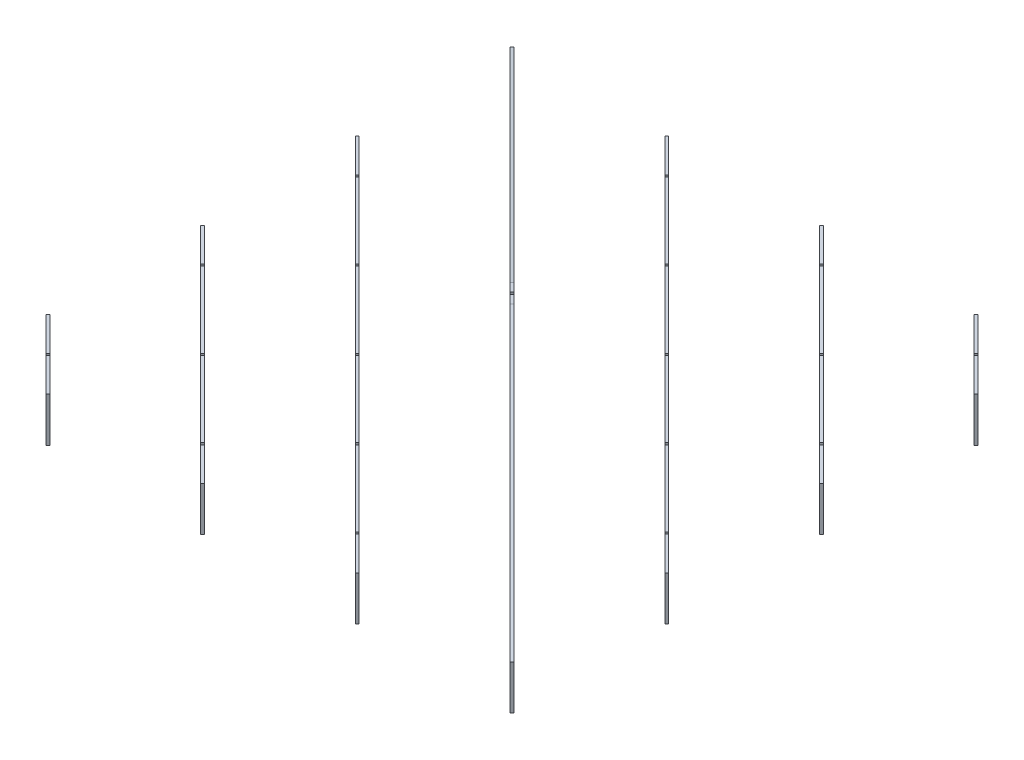
from build123d import *

# Parameters (mm, degrees)
BOSS_EXTRUDE1_DEPTH   = 100
BOSS_EXTRUDE1_2_DEPTH = 100
BOSS_EXTRUDE1_3_DEPTH = 100
BOSS_EXTRUDE1_4_DEPTH = 100
BOSS_EXTRUDE1_5_DEPTH = 100
BOSS_EXTRUDE1_6_DEPTH = 100
BOSS_EXTRUDE1_7_DEPTH = 100
BOSS_EXTRUDE2_START   = -6
BOSS_EXTRUDE2_DEPTH   = 6
SKETCH5_R             = 1.5
SKETCH5_W             = 6
SKETCH5_H             = 100
CUT_EXTRUDE1_DEPTH    = 500.974747
SKETCH6_R             = 1.5
SKETCH6_W             = 6
SKETCH6_H             = 100
CUT_EXTRUDE2_DEPTH    = 500.974747
CUT_EXTRUDE3_DEPTH    = 6
SKETCH8_W             = 56
SKETCH8_H             = 12
CUT_EXTRUDE4_DEPTH    = 6
SKETCH9_R             = 4
SKETCH9_R_2           = 10
CUT_EXTRUDE5_DEPTH    = 6
CUT_EXTRUDE6_START    = -6
SKETCH10_R            = 3
CUT_EXTRUDE6_DEPTH    = 253.487374


with BuildPart() as part:
    # Sketch2 → Boss-Extrude1 (new body)
    with BuildSketch(Plane(origin=(0, 0, 0), x_dir=(1, 0, 0), z_dir=(0, 1, 0))):
        Polygon((-605, -449.242640687), (-449.242640687, -605), (-445, -600.757359313), (-600.757359313, -445), align=None)
    extrude(amount=BOSS_EXTRUDE1_DEPTH)


with BuildPart() as body_2:
    # Sketch2 → Boss-Extrude1 2 (new body)
    with BuildSketch(Plane(origin=(0, 0, 0), x_dir=(1, 0, 0), z_dir=(0, 1, 0))):
        Polygon((-605, -99.242640687), (-99.242640687, -605), (-95, -600.757359313), (-600.757359313, -95), align=None)
    extrude(amount=BOSS_EXTRUDE1_2_DEPTH)


with BuildPart() as body_3:
    # Sketch2 → Boss-Extrude1 3 (new body)
    with BuildSketch(Plane(origin=(0, 0, 0), x_dir=(1, 0, 0), z_dir=(0, 1, 0))):
        Polygon((-605, 250.757359313), (250.757359313, -605), (255, -600.757359313), (-600.757359313, 255), align=None)
    extrude(amount=BOSS_EXTRUDE1_3_DEPTH)


with BuildPart() as body_4:
    # Sketch2 → Boss-Extrude1 4 (new body)
    with BuildSketch(Plane(origin=(0, 0, 0), x_dir=(1, 0, 0), z_dir=(0, 1, 0))):
        Polygon((605, -600.757359313), (-600.757359313, 605), (-605, 600.757359313), (600.757359313, -605), align=None)
    extrude(amount=BOSS_EXTRUDE1_4_DEPTH)

    # Sketch4 → Boss-Extrude2 (add)
    with BuildSketch(Plane(origin=(-2.121320344, 0, 2.121320344), x_dir=(0.707106781, 0, 0.707106781), z_dir=(-0.707106781, 0, 0.707106781)).offset(BOSS_EXTRUDE2_START)):
        Polygon((-30, 220), (-852.599205236, 100), (-30, 100), (30, 100), (852.599205236, 100), (30, 220), align=None)
    extrude(amount=BOSS_EXTRUDE2_DEPTH)

    # Sketch7 → Cut-Extrude3 (cut)
    with BuildSketch(Plane(origin=(-2.121320344, 0, 2.121320344), x_dir=(0.707106781, 0, 0.707106781), z_dir=(-0.707106781, 0, 0.707106781))):
        with BuildLine():
            ThreePointArc((-743.962120246, 50), (-746.522780418, 51.060660172), (-745.462120246, 48.5))
            Line((-745.462120246, 48.5), (-745.462120246, 50))
            Line((-745.462120246, 50), (-743.962120246, 50))
        make_face()
        with BuildLine():
            Line((-745.462120246, 50), (-745.462120246, 48.5))
            ThreePointArc((-745.462120246, 48.5), (-744.401460074, 48.939339828), (-743.962120246, 50))
            Line((-743.962120246, 50), (-745.462120246, 50))
        make_face()
        with BuildLine():
            ThreePointArc((-743.962120246, 50), (-746.522780418, 51.060660172), (-745.462120246, 48.5))
            Line((-745.462120246, 48.5), (-745.462120246, 50))
            Line((-745.462120246, 50), (-743.962120246, 50))
        make_face()
        with BuildLine():
            Line((-745.462120246, 50), (-745.462120246, 48.5))
            ThreePointArc((-745.462120246, 48.5), (-744.401460074, 48.939339828), (-743.962120246, 50))
            Line((-743.962120246, 50), (-745.462120246, 50))
        make_face()
        with BuildLine():
            Line((-745.462120246, 0), (-739.462120246, 0))
            Line((-739.462120246, 0), (-739.462120246, 48.5))
            ThreePointArc((-739.462120246, 48.5), (-740.522780418, 48.939339828), (-740.962120246, 50))
            Line((-740.962120246, 50), (-743.962120246, 50))
            ThreePointArc((-743.962120246, 50), (-744.401460074, 48.939339828), (-745.462120246, 48.5))
            Line((-745.462120246, 48.5), (-745.462120246, 0))
        make_face()
        with BuildLine():
            ThreePointArc((-740.962120246, 50), (-740.522780418, 48.939339828), (-739.462120246, 48.5))
            Line((-739.462120246, 48.5), (-739.462120246, 50))
            Line((-739.462120246, 50), (-740.962120246, 50))
        make_face()
        with BuildLine():
            Line((-739.462120246, 50), (-739.462120246, 48.5))
            ThreePointArc((-739.462120246, 48.5), (-738.401460074, 48.939339828), (-737.962120246, 50))
            ThreePointArc((-737.962120246, 50), (-739.462120246, 51.5), (-740.962120246, 50))
            Line((-740.962120246, 50), (-739.462120246, 50))
        make_face()
        with BuildLine():
            ThreePointArc((-740.962120246, 50), (-740.522780418, 48.939339828), (-739.462120246, 48.5))
            Line((-739.462120246, 48.5), (-739.462120246, 50))
            Line((-739.462120246, 50), (-740.962120246, 50))
        make_face()
        with BuildLine():
            Line((-739.462120246, 50), (-739.462120246, 48.5))
            ThreePointArc((-739.462120246, 48.5), (-738.401460074, 48.939339828), (-737.962120246, 50))
            ThreePointArc((-737.962120246, 50), (-739.462120246, 51.5), (-740.962120246, 50))
            Line((-740.962120246, 50), (-739.462120246, 50))
        make_face()
        with BuildLine():
            ThreePointArc((-496.474746831, 50), (-499.035407002, 51.060660172), (-497.974746831, 48.5))
            Line((-497.974746831, 48.5), (-497.974746831, 50))
            Line((-497.974746831, 50), (-496.474746831, 50))
        make_face()
        with BuildLine():
            Line((-497.974746831, 50), (-497.974746831, 48.5))
            ThreePointArc((-497.974746831, 48.5), (-496.914086659, 48.939339828), (-496.474746831, 50))
            Line((-496.474746831, 50), (-497.974746831, 50))
        make_face()
        with BuildLine():
            ThreePointArc((-496.474746831, 50), (-499.035407002, 51.060660172), (-497.974746831, 48.5))
            Line((-497.974746831, 48.5), (-497.974746831, 50))
            Line((-497.974746831, 50), (-496.474746831, 50))
        make_face()
        with BuildLine():
            Line((-497.974746831, 50), (-497.974746831, 48.5))
            ThreePointArc((-497.974746831, 48.5), (-496.914086659, 48.939339828), (-496.474746831, 50))
            Line((-496.474746831, 50), (-497.974746831, 50))
        make_face()
        with BuildLine():
            Line((-497.974746831, 0), (-491.974746831, 0))
            Line((-491.974746831, 0), (-491.974746831, 48.5))
            ThreePointArc((-491.974746831, 48.5), (-493.035407002, 48.939339828), (-493.474746831, 50))
            Line((-493.474746831, 50), (-496.474746831, 50))
            ThreePointArc((-496.474746831, 50), (-496.914086659, 48.939339828), (-497.974746831, 48.5))
            Line((-497.974746831, 48.5), (-497.974746831, 0))
        make_face()
        with BuildLine():
            ThreePointArc((-493.474746831, 50), (-493.035407002, 48.939339828), (-491.974746831, 48.5))
            Line((-491.974746831, 48.5), (-491.974746831, 50))
            Line((-491.974746831, 50), (-493.474746831, 50))
        make_face()
        with BuildLine():
            Line((-491.974746831, 50), (-491.974746831, 48.5))
            ThreePointArc((-491.974746831, 48.5), (-490.914086659, 48.939339828), (-490.474746831, 50))
            ThreePointArc((-490.474746831, 50), (-491.974746831, 51.5), (-493.474746831, 50))
            Line((-493.474746831, 50), (-491.974746831, 50))
        make_face()
        with BuildLine():
            ThreePointArc((-493.474746831, 50), (-493.035407002, 48.939339828), (-491.974746831, 48.5))
            Line((-491.974746831, 48.5), (-491.974746831, 50))
            Line((-491.974746831, 50), (-493.474746831, 50))
        make_face()
        with BuildLine():
            Line((-491.974746831, 50), (-491.974746831, 48.5))
            ThreePointArc((-491.974746831, 48.5), (-490.914086659, 48.939339828), (-490.474746831, 50))
            ThreePointArc((-490.474746831, 50), (-491.974746831, 51.5), (-493.474746831, 50))
            Line((-493.474746831, 50), (-491.974746831, 50))
        make_face()
        with BuildLine():
            ThreePointArc((-242.987373415, 50), (-244.487373415, 51.5), (-245.987373415, 50))
            Line((-245.987373415, 50), (-244.487373415, 50))
            Line((-244.487373415, 50), (-244.487373415, 48.5))
            ThreePointArc((-244.487373415, 48.5), (-243.426713244, 48.939339828), (-242.987373415, 50))
        make_face()
        with BuildLine():
            Line((-244.487373415, 50), (-245.987373415, 50))
            ThreePointArc((-245.987373415, 50), (-245.548033587, 48.939339828), (-244.487373415, 48.5))
            Line((-244.487373415, 48.5), (-244.487373415, 50))
        make_face()
        with BuildLine():
            ThreePointArc((-242.987373415, 50), (-244.487373415, 51.5), (-245.987373415, 50))
            Line((-245.987373415, 50), (-244.487373415, 50))
            Line((-244.487373415, 50), (-244.487373415, 48.5))
            ThreePointArc((-244.487373415, 48.5), (-243.426713244, 48.939339828), (-242.987373415, 50))
        make_face()
        with BuildLine():
            Line((-244.487373415, 50), (-245.987373415, 50))
            ThreePointArc((-245.987373415, 50), (-245.548033587, 48.939339828), (-244.487373415, 48.5))
            Line((-244.487373415, 48.5), (-244.487373415, 50))
        make_face()
        with BuildLine():
            Line((-245.987373415, 50), (-248.987373415, 50))
            ThreePointArc((-248.987373415, 50), (-249.426713244, 48.939339828), (-250.487373415, 48.5))
            Line((-250.487373415, 48.5), (-250.487373415, 0))
            Line((-250.487373415, 0), (-244.487373415, 0))
            Line((-244.487373415, 0), (-244.487373415, 48.5))
            ThreePointArc((-244.487373415, 48.5), (-245.548033587, 48.939339828), (-245.987373415, 50))
        make_face()
        with BuildLine():
            Line((-250.487373415, 48.5), (-250.487373415, 50))
            Line((-250.487373415, 50), (-248.987373415, 50))
            ThreePointArc((-248.987373415, 50), (-251.548033587, 51.060660172), (-250.487373415, 48.5))
        make_face()
        with BuildLine():
            Line((-248.987373415, 50), (-250.487373415, 50))
            Line((-250.487373415, 50), (-250.487373415, 48.5))
            ThreePointArc((-250.487373415, 48.5), (-249.426713244, 48.939339828), (-248.987373415, 50))
        make_face()
        with BuildLine():
            Line((-250.487373415, 48.5), (-250.487373415, 50))
            Line((-250.487373415, 50), (-248.987373415, 50))
            ThreePointArc((-248.987373415, 50), (-251.548033587, 51.060660172), (-250.487373415, 48.5))
        make_face()
        with BuildLine():
            Line((-248.987373415, 50), (-250.487373415, 50))
            Line((-250.487373415, 50), (-250.487373415, 48.5))
            ThreePointArc((-250.487373415, 48.5), (-249.426713244, 48.939339828), (-248.987373415, 50))
        make_face()
        with BuildLine():
            Line((3, 220), (-3, 220))
            Line((-3, 220), (-3, 111.5))
            ThreePointArc((-3, 111.5), (-1.939339828, 111.060660172), (-1.5, 110))
            Line((-1.5, 110), (1.5, 110))
            ThreePointArc((1.5, 110), (1.939339828, 111.060660172), (3, 111.5))
            Line((3, 111.5), (3, 220))
        make_face()
        with BuildLine():
            ThreePointArc((-1.5, 110), (-1.939339828, 111.060660172), (-3, 111.5))
            Line((-3, 111.5), (-3, 110))
            Line((-3, 110), (-1.5, 110))
        make_face()
        with BuildLine():
            Line((-3, 110), (-3, 111.5))
            ThreePointArc((-3, 111.5), (-4.060660172, 108.939339828), (-1.5, 110))
            Line((-1.5, 110), (-3, 110))
        make_face()
        with BuildLine():
            ThreePointArc((-1.5, 110), (-1.939339828, 111.060660172), (-3, 111.5))
            Line((-3, 111.5), (-3, 110))
            Line((-3, 110), (-1.5, 110))
        make_face()
        with BuildLine():
            Line((-3, 110), (-3, 111.5))
            ThreePointArc((-3, 111.5), (-4.060660172, 108.939339828), (-1.5, 110))
            Line((-1.5, 110), (-3, 110))
        make_face()
        with BuildLine():
            ThreePointArc((4.5, 110), (4.060660172, 111.060660172), (3, 111.5))
            Line((3, 111.5), (3, 110))
            Line((3, 110), (1.5, 110))
            ThreePointArc((1.5, 110), (3, 108.5), (4.5, 110))
        make_face()
        with BuildLine():
            Line((3, 110), (3, 111.5))
            ThreePointArc((3, 111.5), (1.939339828, 111.060660172), (1.5, 110))
            Line((1.5, 110), (3, 110))
        make_face()
        with BuildLine():
            ThreePointArc((4.5, 110), (4.060660172, 111.060660172), (3, 111.5))
            Line((3, 111.5), (3, 110))
            Line((3, 110), (1.5, 110))
            ThreePointArc((1.5, 110), (3, 108.5), (4.5, 110))
        make_face()
        with BuildLine():
            Line((3, 110), (3, 111.5))
            ThreePointArc((3, 111.5), (1.939339828, 111.060660172), (1.5, 110))
            Line((1.5, 110), (3, 110))
        make_face()
        with BuildLine():
            ThreePointArc((245.987373415, 50), (243.426713244, 51.060660172), (244.487373415, 48.5))
            Line((244.487373415, 48.5), (244.487373415, 50))
            Line((244.487373415, 50), (245.987373415, 50))
        make_face()
        with BuildLine():
            Line((244.487373415, 50), (244.487373415, 48.5))
            ThreePointArc((244.487373415, 48.5), (245.548033587, 48.939339828), (245.987373415, 50))
            Line((245.987373415, 50), (244.487373415, 50))
        make_face()
        with BuildLine():
            ThreePointArc((245.987373415, 50), (243.426713244, 51.060660172), (244.487373415, 48.5))
            Line((244.487373415, 48.5), (244.487373415, 50))
            Line((244.487373415, 50), (245.987373415, 50))
        make_face()
        with BuildLine():
            Line((244.487373415, 50), (244.487373415, 48.5))
            ThreePointArc((244.487373415, 48.5), (245.548033587, 48.939339828), (245.987373415, 50))
            Line((245.987373415, 50), (244.487373415, 50))
        make_face()
        with BuildLine():
            Line((244.487373415, 48.5), (244.487373415, 0))
            Line((244.487373415, 0), (250.487373415, 0))
            Line((250.487373415, 0), (250.487373415, 48.5))
            ThreePointArc((250.487373415, 48.5), (249.426713244, 48.939339828), (248.987373415, 50))
            Line((248.987373415, 50), (245.987373415, 50))
            ThreePointArc((245.987373415, 50), (245.548033587, 48.939339828), (244.487373415, 48.5))
        make_face()
        with BuildLine():
            ThreePointArc((248.987373415, 50), (249.426713244, 48.939339828), (250.487373415, 48.5))
            Line((250.487373415, 48.5), (250.487373415, 50))
            Line((250.487373415, 50), (248.987373415, 50))
        make_face()
        with BuildLine():
            Line((250.487373415, 50), (250.487373415, 48.5))
            ThreePointArc((250.487373415, 48.5), (251.548033587, 48.939339828), (251.987373415, 50))
            ThreePointArc((251.987373415, 50), (250.487373415, 51.5), (248.987373415, 50))
            Line((248.987373415, 50), (250.487373415, 50))
        make_face()
        with BuildLine():
            ThreePointArc((248.987373415, 50), (249.426713244, 48.939339828), (250.487373415, 48.5))
            Line((250.487373415, 48.5), (250.487373415, 50))
            Line((250.487373415, 50), (248.987373415, 50))
        make_face()
        with BuildLine():
            Line((250.487373415, 50), (250.487373415, 48.5))
            ThreePointArc((250.487373415, 48.5), (251.548033587, 48.939339828), (251.987373415, 50))
            ThreePointArc((251.987373415, 50), (250.487373415, 51.5), (248.987373415, 50))
            Line((248.987373415, 50), (250.487373415, 50))
        make_face()
        with BuildLine():
            ThreePointArc((493.474746831, 50), (490.914086659, 51.060660172), (491.974746831, 48.5))
            Line((491.974746831, 48.5), (491.974746831, 50))
            Line((491.974746831, 50), (493.474746831, 50))
        make_face()
        with BuildLine():
            Line((491.974746831, 50), (491.974746831, 48.5))
            ThreePointArc((491.974746831, 48.5), (493.035407002, 48.939339828), (493.474746831, 50))
            Line((493.474746831, 50), (491.974746831, 50))
        make_face()
        with BuildLine():
            ThreePointArc((493.474746831, 50), (490.914086659, 51.060660172), (491.974746831, 48.5))
            Line((491.974746831, 48.5), (491.974746831, 50))
            Line((491.974746831, 50), (493.474746831, 50))
        make_face()
        with BuildLine():
            Line((491.974746831, 50), (491.974746831, 48.5))
            ThreePointArc((491.974746831, 48.5), (493.035407002, 48.939339828), (493.474746831, 50))
            Line((493.474746831, 50), (491.974746831, 50))
        make_face()
        with BuildLine():
            Line((491.974746831, 48.5), (491.974746831, 0))
            Line((491.974746831, 0), (497.974746831, 0))
            Line((497.974746831, 0), (497.974746831, 48.5))
            ThreePointArc((497.974746831, 48.5), (496.914086659, 48.939339828), (496.474746831, 50))
            Line((496.474746831, 50), (493.474746831, 50))
            ThreePointArc((493.474746831, 50), (493.035407002, 48.939339828), (491.974746831, 48.5))
        make_face()
        with BuildLine():
            ThreePointArc((496.474746831, 50), (496.914086659, 48.939339828), (497.974746831, 48.5))
            Line((497.974746831, 48.5), (497.974746831, 50))
            Line((497.974746831, 50), (496.474746831, 50))
        make_face()
        with BuildLine():
            Line((497.974746831, 50), (497.974746831, 48.5))
            ThreePointArc((497.974746831, 48.5), (499.035407002, 48.939339828), (499.474746831, 50))
            ThreePointArc((499.474746831, 50), (497.974746831, 51.5), (496.474746831, 50))
            Line((496.474746831, 50), (497.974746831, 50))
        make_face()
        with BuildLine():
            ThreePointArc((496.474746831, 50), (496.914086659, 48.939339828), (497.974746831, 48.5))
            Line((497.974746831, 48.5), (497.974746831, 50))
            Line((497.974746831, 50), (496.474746831, 50))
        make_face()
        with BuildLine():
            Line((497.974746831, 50), (497.974746831, 48.5))
            ThreePointArc((497.974746831, 48.5), (499.035407002, 48.939339828), (499.474746831, 50))
            ThreePointArc((499.474746831, 50), (497.974746831, 51.5), (496.474746831, 50))
            Line((496.474746831, 50), (497.974746831, 50))
        make_face()
        with BuildLine():
            ThreePointArc((740.962120246, 50), (738.401460074, 51.060660172), (739.462120246, 48.5))
            Line((739.462120246, 48.5), (739.462120246, 50))
            Line((739.462120246, 50), (740.962120246, 50))
        make_face()
        with BuildLine():
            Line((739.462120246, 50), (739.462120246, 48.5))
            ThreePointArc((739.462120246, 48.5), (740.522780418, 48.939339828), (740.962120246, 50))
            Line((740.962120246, 50), (739.462120246, 50))
        make_face()
        with BuildLine():
            ThreePointArc((740.962120246, 50), (738.401460074, 51.060660172), (739.462120246, 48.5))
            Line((739.462120246, 48.5), (739.462120246, 50))
            Line((739.462120246, 50), (740.962120246, 50))
        make_face()
        with BuildLine():
            Line((739.462120246, 50), (739.462120246, 48.5))
            ThreePointArc((739.462120246, 48.5), (740.522780418, 48.939339828), (740.962120246, 50))
            Line((740.962120246, 50), (739.462120246, 50))
        make_face()
        with BuildLine():
            Line((739.462120246, 48.5), (739.462120246, 0))
            Line((739.462120246, 0), (745.462120246, 0))
            Line((745.462120246, 0), (745.462120246, 48.5))
            ThreePointArc((745.462120246, 48.5), (744.401460074, 48.939339828), (743.962120246, 50))
            Line((743.962120246, 50), (740.962120246, 50))
            ThreePointArc((740.962120246, 50), (740.522780418, 48.939339828), (739.462120246, 48.5))
        make_face()
        with BuildLine():
            ThreePointArc((743.962120246, 50), (744.401460074, 48.939339828), (745.462120246, 48.5))
            Line((745.462120246, 48.5), (745.462120246, 50))
            Line((745.462120246, 50), (743.962120246, 50))
        make_face()
        with BuildLine():
            Line((745.462120246, 50), (745.462120246, 48.5))
            ThreePointArc((745.462120246, 48.5), (746.522780418, 48.939339828), (746.962120246, 50))
            ThreePointArc((746.962120246, 50), (745.462120246, 51.5), (743.962120246, 50))
            Line((743.962120246, 50), (745.462120246, 50))
        make_face()
        with BuildLine():
            ThreePointArc((743.962120246, 50), (744.401460074, 48.939339828), (745.462120246, 48.5))
            Line((745.462120246, 48.5), (745.462120246, 50))
            Line((745.462120246, 50), (743.962120246, 50))
        make_face()
        with BuildLine():
            Line((745.462120246, 50), (745.462120246, 48.5))
            ThreePointArc((745.462120246, 48.5), (746.522780418, 48.939339828), (746.962120246, 50))
            ThreePointArc((746.962120246, 50), (745.462120246, 51.5), (743.962120246, 50))
            Line((743.962120246, 50), (745.462120246, 50))
        make_face()
    extrude(amount=-CUT_EXTRUDE3_DEPTH, mode=Mode.SUBTRACT)

    # Sketch8 → Cut-Extrude4 (cut)
    with BuildSketch(Plane(origin=(-2.121320344, 0, 2.121320344), x_dir=(0.707106781, 0, 0.707106781), z_dir=(-0.707106781, 0, 0.707106781))):
        with Locations((371.231060123, 22)):
            Rectangle(SKETCH8_W, SKETCH8_H)
        with Locations((-371.231060123, 22)):
            Rectangle(SKETCH8_W, SKETCH8_H)
    extrude(amount=-CUT_EXTRUDE4_DEPTH, mode=Mode.SUBTRACT)

    # Sketch9 → Cut-Extrude5 (cut)
    with BuildSketch(Plane(origin=(2.121320344, 0, -2.121320344), x_dir=(-0.707106781, 0, -0.707106781), z_dir=(0.707106781, 0, -0.707106781))):
        with Locations((123.743686708, 64)):
            Circle(SKETCH9_R)
        with Locations((123.743686708, 84)):
            Circle(SKETCH9_R)
        with Locations((40, 74)):
            Circle(SKETCH9_R_2)
        with Locations((-40, 74)):
            Circle(SKETCH9_R_2)
        with Locations((-123.743686708, 84)):
            Circle(SKETCH9_R)
        with Locations((-123.743686708, 64)):
            Circle(SKETCH9_R)
    extrude(amount=-CUT_EXTRUDE5_DEPTH, mode=Mode.SUBTRACT)


with BuildPart() as body_5:
    # Sketch2 → Boss-Extrude1 5 (new body)
    with BuildSketch(Plane(origin=(0, 0, 0), x_dir=(1, 0, 0), z_dir=(0, 1, 0))):
        Polygon((-255, 600.757359313), (600.757359313, -255), (605, -250.757359313), (-250.757359313, 605), align=None)
    extrude(amount=BOSS_EXTRUDE1_5_DEPTH)


with BuildPart() as body_6:
    # Sketch2 → Boss-Extrude1 6 (new body)
    with BuildSketch(Plane(origin=(0, 0, 0), x_dir=(1, 0, 0), z_dir=(0, 1, 0))):
        Polygon((95, 600.757359313), (600.757359313, 95), (605, 99.242640687), (99.242640687, 605), align=None)
    extrude(amount=BOSS_EXTRUDE1_6_DEPTH)


with BuildPart() as body_7:
    # Sketch2 → Boss-Extrude1 7 (new body)
    with BuildSketch(Plane(origin=(0, 0, 0), x_dir=(1, 0, 0), z_dir=(0, 1, 0))):
        Polygon((445, 600.757359313), (600.757359313, 445), (605, 449.242640687), (449.242640687, 605), align=None)
    extrude(amount=BOSS_EXTRUDE1_7_DEPTH)


with BuildPart() as cut_extrude1_tool:
    # Sketch5 → Cut-Extrude1 (new body)
    with BuildSketch(Plane(origin=(-527.121320344, 0, 527.121320344), x_dir=(0.707106781, 0, 0.707106781), z_dir=(-0.707106781, 0, 0.707106781))):
        with Locations((497.974746831, 50)):
            Circle(SKETCH5_R)
        with Locations((491.974746831, 50)):
            Circle(SKETCH5_R)
        with Locations((494.974746831, 100)):
            Rectangle(SKETCH5_W, SKETCH5_H)
        with BuildLine():
            ThreePointArc((493.474746831, 50), (493.035407002, 51.060660172), (491.974746831, 51.5))
            Line((491.974746831, 51.5), (491.974746831, 50))
            Line((491.974746831, 50), (493.474746831, 50))
        make_face()
        with BuildLine():
            Line((491.974746831, 50), (491.974746831, 51.5))
            ThreePointArc((491.974746831, 51.5), (490.914086659, 48.939339828), (493.474746831, 50))
            Line((493.474746831, 50), (491.974746831, 50))
        make_face()
        with BuildLine():
            ThreePointArc((493.474746831, 50), (493.035407002, 51.060660172), (491.974746831, 51.5))
            Line((491.974746831, 51.5), (491.974746831, 50))
            Line((491.974746831, 50), (493.474746831, 50))
        make_face()
        with BuildLine():
            Line((491.974746831, 50), (491.974746831, 51.5))
            ThreePointArc((491.974746831, 51.5), (490.914086659, 48.939339828), (493.474746831, 50))
            Line((493.474746831, 50), (491.974746831, 50))
        make_face()
        with BuildLine():
            ThreePointArc((499.474746831, 50), (499.035407002, 51.060660172), (497.974746831, 51.5))
            Line((497.974746831, 51.5), (497.974746831, 50))
            Line((497.974746831, 50), (496.474746831, 50))
            ThreePointArc((496.474746831, 50), (497.974746831, 48.5), (499.474746831, 50))
        make_face()
        with BuildLine():
            Line((497.974746831, 50), (497.974746831, 51.5))
            ThreePointArc((497.974746831, 51.5), (496.914086659, 51.060660172), (496.474746831, 50))
            Line((496.474746831, 50), (497.974746831, 50))
        make_face()
        with BuildLine():
            ThreePointArc((499.474746831, 50), (499.035407002, 51.060660172), (497.974746831, 51.5))
            Line((497.974746831, 51.5), (497.974746831, 50))
            Line((497.974746831, 50), (496.474746831, 50))
            ThreePointArc((496.474746831, 50), (497.974746831, 48.5), (499.474746831, 50))
        make_face()
        with BuildLine():
            Line((497.974746831, 50), (497.974746831, 51.5))
            ThreePointArc((497.974746831, 51.5), (496.914086659, 51.060660172), (496.474746831, 50))
            Line((496.474746831, 50), (497.974746831, 50))
        make_face()
        with Locations((250.487373415, 50)):
            Circle(SKETCH5_R)
        with Locations((244.487373415, 50)):
            Circle(SKETCH5_R)
        with Locations((247.487373415, 100)):
            Rectangle(SKETCH5_W, SKETCH5_H)
        with BuildLine():
            ThreePointArc((245.987373415, 50), (245.548033587, 51.060660172), (244.487373415, 51.5))
            Line((244.487373415, 51.5), (244.487373415, 50))
            Line((244.487373415, 50), (245.987373415, 50))
        make_face()
        with BuildLine():
            Line((244.487373415, 50), (244.487373415, 51.5))
            ThreePointArc((244.487373415, 51.5), (243.426713244, 48.939339828), (245.987373415, 50))
            Line((245.987373415, 50), (244.487373415, 50))
        make_face()
        with BuildLine():
            ThreePointArc((245.987373415, 50), (245.548033587, 51.060660172), (244.487373415, 51.5))
            Line((244.487373415, 51.5), (244.487373415, 50))
            Line((244.487373415, 50), (245.987373415, 50))
        make_face()
        with BuildLine():
            Line((244.487373415, 50), (244.487373415, 51.5))
            ThreePointArc((244.487373415, 51.5), (243.426713244, 48.939339828), (245.987373415, 50))
            Line((245.987373415, 50), (244.487373415, 50))
        make_face()
        with BuildLine():
            ThreePointArc((251.987373415, 50), (251.548033587, 51.060660172), (250.487373415, 51.5))
            Line((250.487373415, 51.5), (250.487373415, 50))
            Line((250.487373415, 50), (248.987373415, 50))
            ThreePointArc((248.987373415, 50), (250.487373415, 48.5), (251.987373415, 50))
        make_face()
        with BuildLine():
            Line((250.487373415, 50), (250.487373415, 51.5))
            ThreePointArc((250.487373415, 51.5), (249.426713244, 51.060660172), (248.987373415, 50))
            Line((248.987373415, 50), (250.487373415, 50))
        make_face()
        with BuildLine():
            ThreePointArc((251.987373415, 50), (251.548033587, 51.060660172), (250.487373415, 51.5))
            Line((250.487373415, 51.5), (250.487373415, 50))
            Line((250.487373415, 50), (248.987373415, 50))
            ThreePointArc((248.987373415, 50), (250.487373415, 48.5), (251.987373415, 50))
        make_face()
        with BuildLine():
            Line((250.487373415, 50), (250.487373415, 51.5))
            ThreePointArc((250.487373415, 51.5), (249.426713244, 51.060660172), (248.987373415, 50))
            Line((248.987373415, 50), (250.487373415, 50))
        make_face()
        with BuildLine():
            Line((3, 100), (-3, 100))
            Line((-3, 100), (-3, 51.5))
            ThreePointArc((-3, 51.5), (-1.939339828, 51.060660172), (-1.5, 50))
            Line((-1.5, 50), (1.5, 50))
            ThreePointArc((1.5, 50), (1.939339828, 51.060660172), (3, 51.5))
            Line((3, 51.5), (3, 100))
        make_face()
        with BuildLine():
            ThreePointArc((-1.5, 50), (-1.939339828, 51.060660172), (-3, 51.5))
            Line((-3, 51.5), (-3, 50))
            Line((-3, 50), (-1.5, 50))
        make_face()
        with BuildLine():
            Line((-3, 50), (-3, 51.5))
            ThreePointArc((-3, 51.5), (-4.060660172, 48.939339828), (-1.5, 50))
            Line((-1.5, 50), (-3, 50))
        make_face()
        with BuildLine():
            ThreePointArc((-1.5, 50), (-1.939339828, 51.060660172), (-3, 51.5))
            Line((-3, 51.5), (-3, 50))
            Line((-3, 50), (-1.5, 50))
        make_face()
        with BuildLine():
            Line((-3, 50), (-3, 51.5))
            ThreePointArc((-3, 51.5), (-4.060660172, 48.939339828), (-1.5, 50))
            Line((-1.5, 50), (-3, 50))
        make_face()
        with BuildLine():
            ThreePointArc((4.5, 50), (4.060660172, 51.060660172), (3, 51.5))
            Line((3, 51.5), (3, 50))
            Line((3, 50), (1.5, 50))
            ThreePointArc((1.5, 50), (3, 48.5), (4.5, 50))
        make_face()
        with BuildLine():
            Line((3, 50), (3, 51.5))
            ThreePointArc((3, 51.5), (1.939339828, 51.060660172), (1.5, 50))
            Line((1.5, 50), (3, 50))
        make_face()
        with BuildLine():
            ThreePointArc((4.5, 50), (4.060660172, 51.060660172), (3, 51.5))
            Line((3, 51.5), (3, 50))
            Line((3, 50), (1.5, 50))
            ThreePointArc((1.5, 50), (3, 48.5), (4.5, 50))
        make_face()
        with BuildLine():
            Line((3, 50), (3, 51.5))
            ThreePointArc((3, 51.5), (1.939339828, 51.060660172), (1.5, 50))
            Line((1.5, 50), (3, 50))
        make_face()
        with Locations((-244.487373415, 50)):
            Circle(SKETCH5_R)
        with Locations((-250.487373415, 50)):
            Circle(SKETCH5_R)
        with Locations((-247.487373415, 100)):
            Rectangle(SKETCH5_W, SKETCH5_H)
        with BuildLine():
            ThreePointArc((-248.987373415, 50), (-249.426713244, 51.060660172), (-250.487373415, 51.5))
            Line((-250.487373415, 51.5), (-250.487373415, 50))
            Line((-250.487373415, 50), (-248.987373415, 50))
        make_face()
        with BuildLine():
            Line((-250.487373415, 50), (-250.487373415, 51.5))
            ThreePointArc((-250.487373415, 51.5), (-251.548033587, 48.939339828), (-248.987373415, 50))
            Line((-248.987373415, 50), (-250.487373415, 50))
        make_face()
        with BuildLine():
            ThreePointArc((-248.987373415, 50), (-249.426713244, 51.060660172), (-250.487373415, 51.5))
            Line((-250.487373415, 51.5), (-250.487373415, 50))
            Line((-250.487373415, 50), (-248.987373415, 50))
        make_face()
        with BuildLine():
            Line((-250.487373415, 50), (-250.487373415, 51.5))
            ThreePointArc((-250.487373415, 51.5), (-251.548033587, 48.939339828), (-248.987373415, 50))
            Line((-248.987373415, 50), (-250.487373415, 50))
        make_face()
        with BuildLine():
            ThreePointArc((-242.987373415, 50), (-243.426713244, 51.060660172), (-244.487373415, 51.5))
            Line((-244.487373415, 51.5), (-244.487373415, 50))
            Line((-244.487373415, 50), (-245.987373415, 50))
            ThreePointArc((-245.987373415, 50), (-244.487373415, 48.5), (-242.987373415, 50))
        make_face()
        with BuildLine():
            Line((-244.487373415, 50), (-244.487373415, 51.5))
            ThreePointArc((-244.487373415, 51.5), (-245.548033587, 51.060660172), (-245.987373415, 50))
            Line((-245.987373415, 50), (-244.487373415, 50))
        make_face()
        with BuildLine():
            ThreePointArc((-242.987373415, 50), (-243.426713244, 51.060660172), (-244.487373415, 51.5))
            Line((-244.487373415, 51.5), (-244.487373415, 50))
            Line((-244.487373415, 50), (-245.987373415, 50))
            ThreePointArc((-245.987373415, 50), (-244.487373415, 48.5), (-242.987373415, 50))
        make_face()
        with BuildLine():
            Line((-244.487373415, 50), (-244.487373415, 51.5))
            ThreePointArc((-244.487373415, 51.5), (-245.548033587, 51.060660172), (-245.987373415, 50))
            Line((-245.987373415, 50), (-244.487373415, 50))
        make_face()
        with Locations((-491.974746831, 50)):
            Circle(SKETCH5_R)
        with Locations((-497.974746831, 50)):
            Circle(SKETCH5_R)
        with Locations((-494.974746831, 100)):
            Rectangle(SKETCH5_W, SKETCH5_H)
        with BuildLine():
            ThreePointArc((-496.474746831, 50), (-496.914086659, 51.060660172), (-497.974746831, 51.5))
            Line((-497.974746831, 51.5), (-497.974746831, 50))
            Line((-497.974746831, 50), (-496.474746831, 50))
        make_face()
        with BuildLine():
            Line((-497.974746831, 50), (-497.974746831, 51.5))
            ThreePointArc((-497.974746831, 51.5), (-499.035407002, 48.939339828), (-496.474746831, 50))
            Line((-496.474746831, 50), (-497.974746831, 50))
        make_face()
        with BuildLine():
            ThreePointArc((-496.474746831, 50), (-496.914086659, 51.060660172), (-497.974746831, 51.5))
            Line((-497.974746831, 51.5), (-497.974746831, 50))
            Line((-497.974746831, 50), (-496.474746831, 50))
        make_face()
        with BuildLine():
            Line((-497.974746831, 50), (-497.974746831, 51.5))
            ThreePointArc((-497.974746831, 51.5), (-499.035407002, 48.939339828), (-496.474746831, 50))
            Line((-496.474746831, 50), (-497.974746831, 50))
        make_face()
        with BuildLine():
            ThreePointArc((-490.474746831, 50), (-490.914086659, 51.060660172), (-491.974746831, 51.5))
            Line((-491.974746831, 51.5), (-491.974746831, 50))
            Line((-491.974746831, 50), (-493.474746831, 50))
            ThreePointArc((-493.474746831, 50), (-491.974746831, 48.5), (-490.474746831, 50))
        make_face()
        with BuildLine():
            Line((-491.974746831, 50), (-491.974746831, 51.5))
            ThreePointArc((-491.974746831, 51.5), (-493.035407002, 51.060660172), (-493.474746831, 50))
            Line((-493.474746831, 50), (-491.974746831, 50))
        make_face()
        with BuildLine():
            ThreePointArc((-490.474746831, 50), (-490.914086659, 51.060660172), (-491.974746831, 51.5))
            Line((-491.974746831, 51.5), (-491.974746831, 50))
            Line((-491.974746831, 50), (-493.474746831, 50))
            ThreePointArc((-493.474746831, 50), (-491.974746831, 48.5), (-490.474746831, 50))
        make_face()
        with BuildLine():
            Line((-491.974746831, 50), (-491.974746831, 51.5))
            ThreePointArc((-491.974746831, 51.5), (-493.035407002, 51.060660172), (-493.474746831, 50))
            Line((-493.474746831, 50), (-491.974746831, 50))
        make_face()
    extrude(amount=-CUT_EXTRUDE1_DEPTH)


with BuildPart() as part_1:
    add(part.part)

    # Cut-Extrude1: cut by cut_extrude1_tool
    add(cut_extrude1_tool.part, mode=Mode.SUBTRACT)


with BuildPart() as body_2_1:
    add(body_2.part)

    # Cut-Extrude1: cut by cut_extrude1_tool
    add(cut_extrude1_tool.part, mode=Mode.SUBTRACT)


with BuildPart() as body_3_1:
    add(body_3.part)

    # Cut-Extrude1: cut by cut_extrude1_tool
    add(cut_extrude1_tool.part, mode=Mode.SUBTRACT)


with BuildPart() as cut_extrude2_tool:
    # Sketch6 → Cut-Extrude2 (new body)
    with BuildSketch(Plane(origin=(527.121320344, 0, -527.121320344), x_dir=(-0.707106781, 0, -0.707106781), z_dir=(0.707106781, 0, -0.707106781))):
        with Locations((-491.974746831, 50)):
            Circle(SKETCH6_R)
        with Locations((-497.974746831, 50)):
            Circle(SKETCH6_R)
        with Locations((-494.974746831, 100)):
            Rectangle(SKETCH6_W, SKETCH6_H)
        with BuildLine():
            ThreePointArc((-497.974746831, 51.5), (-499.035407002, 48.939339828), (-496.474746831, 50))
            Line((-496.474746831, 50), (-497.974746831, 50))
            Line((-497.974746831, 50), (-497.974746831, 51.5))
        make_face()
        with BuildLine():
            Line((-497.974746831, 50), (-496.474746831, 50))
            ThreePointArc((-496.474746831, 50), (-496.914086659, 51.060660172), (-497.974746831, 51.5))
            Line((-497.974746831, 51.5), (-497.974746831, 50))
        make_face()
        with BuildLine():
            ThreePointArc((-497.974746831, 51.5), (-499.035407002, 48.939339828), (-496.474746831, 50))
            Line((-496.474746831, 50), (-497.974746831, 50))
            Line((-497.974746831, 50), (-497.974746831, 51.5))
        make_face()
        with BuildLine():
            Line((-497.974746831, 50), (-496.474746831, 50))
            ThreePointArc((-496.474746831, 50), (-496.914086659, 51.060660172), (-497.974746831, 51.5))
            Line((-497.974746831, 51.5), (-497.974746831, 50))
        make_face()
        with BuildLine():
            Line((-493.474746831, 50), (-491.974746831, 50))
            Line((-491.974746831, 50), (-491.974746831, 51.5))
            ThreePointArc((-491.974746831, 51.5), (-493.035407002, 51.060660172), (-493.474746831, 50))
        make_face()
        with BuildLine():
            Line((-491.974746831, 51.5), (-491.974746831, 50))
            Line((-491.974746831, 50), (-493.474746831, 50))
            ThreePointArc((-493.474746831, 50), (-491.974746831, 48.5), (-490.474746831, 50))
            ThreePointArc((-490.474746831, 50), (-490.914086659, 51.060660172), (-491.974746831, 51.5))
        make_face()
        with BuildLine():
            Line((-493.474746831, 50), (-491.974746831, 50))
            Line((-491.974746831, 50), (-491.974746831, 51.5))
            ThreePointArc((-491.974746831, 51.5), (-493.035407002, 51.060660172), (-493.474746831, 50))
        make_face()
        with BuildLine():
            Line((-491.974746831, 51.5), (-491.974746831, 50))
            Line((-491.974746831, 50), (-493.474746831, 50))
            ThreePointArc((-493.474746831, 50), (-491.974746831, 48.5), (-490.474746831, 50))
            ThreePointArc((-490.474746831, 50), (-490.914086659, 51.060660172), (-491.974746831, 51.5))
        make_face()
        with Locations((-244.487373415, 50)):
            Circle(SKETCH6_R)
        with Locations((-250.487373415, 50)):
            Circle(SKETCH6_R)
        with Locations((-247.487373415, 100)):
            Rectangle(SKETCH6_W, SKETCH6_H)
        with BuildLine():
            ThreePointArc((-250.487373415, 51.5), (-251.548033587, 48.939339828), (-248.987373415, 50))
            Line((-248.987373415, 50), (-250.487373415, 50))
            Line((-250.487373415, 50), (-250.487373415, 51.5))
        make_face()
        with BuildLine():
            Line((-250.487373415, 50), (-248.987373415, 50))
            ThreePointArc((-248.987373415, 50), (-249.426713244, 51.060660172), (-250.487373415, 51.5))
            Line((-250.487373415, 51.5), (-250.487373415, 50))
        make_face()
        with BuildLine():
            ThreePointArc((-250.487373415, 51.5), (-251.548033587, 48.939339828), (-248.987373415, 50))
            Line((-248.987373415, 50), (-250.487373415, 50))
            Line((-250.487373415, 50), (-250.487373415, 51.5))
        make_face()
        with BuildLine():
            Line((-250.487373415, 50), (-248.987373415, 50))
            ThreePointArc((-248.987373415, 50), (-249.426713244, 51.060660172), (-250.487373415, 51.5))
            Line((-250.487373415, 51.5), (-250.487373415, 50))
        make_face()
        with BuildLine():
            Line((-245.987373415, 50), (-244.487373415, 50))
            Line((-244.487373415, 50), (-244.487373415, 51.5))
            ThreePointArc((-244.487373415, 51.5), (-245.548033587, 51.060660172), (-245.987373415, 50))
        make_face()
        with BuildLine():
            Line((-244.487373415, 51.5), (-244.487373415, 50))
            Line((-244.487373415, 50), (-245.987373415, 50))
            ThreePointArc((-245.987373415, 50), (-244.487373415, 48.5), (-242.987373415, 50))
            ThreePointArc((-242.987373415, 50), (-243.426713244, 51.060660172), (-244.487373415, 51.5))
        make_face()
        with BuildLine():
            Line((-245.987373415, 50), (-244.487373415, 50))
            Line((-244.487373415, 50), (-244.487373415, 51.5))
            ThreePointArc((-244.487373415, 51.5), (-245.548033587, 51.060660172), (-245.987373415, 50))
        make_face()
        with BuildLine():
            Line((-244.487373415, 51.5), (-244.487373415, 50))
            Line((-244.487373415, 50), (-245.987373415, 50))
            ThreePointArc((-245.987373415, 50), (-244.487373415, 48.5), (-242.987373415, 50))
            ThreePointArc((-242.987373415, 50), (-243.426713244, 51.060660172), (-244.487373415, 51.5))
        make_face()
        with BuildLine():
            Line((3, 100), (-3, 100))
            Line((-3, 100), (-3, 51.5))
            ThreePointArc((-3, 51.5), (-1.939339828, 51.060660172), (-1.5, 50))
            Line((-1.5, 50), (1.5, 50))
            ThreePointArc((1.5, 50), (1.939339828, 51.060660172), (3, 51.5))
            Line((3, 51.5), (3, 100))
        make_face()
        with BuildLine():
            ThreePointArc((4.5, 50), (4.060660172, 51.060660172), (3, 51.5))
            Line((3, 51.5), (3, 50))
            Line((3, 50), (1.5, 50))
            ThreePointArc((1.5, 50), (3, 48.5), (4.5, 50))
        make_face()
        with BuildLine():
            Line((3, 50), (3, 51.5))
            ThreePointArc((3, 51.5), (1.939339828, 51.060660172), (1.5, 50))
            Line((1.5, 50), (3, 50))
        make_face()
        with BuildLine():
            ThreePointArc((4.5, 50), (4.060660172, 51.060660172), (3, 51.5))
            Line((3, 51.5), (3, 50))
            Line((3, 50), (1.5, 50))
            ThreePointArc((1.5, 50), (3, 48.5), (4.5, 50))
        make_face()
        with BuildLine():
            Line((3, 50), (3, 51.5))
            ThreePointArc((3, 51.5), (1.939339828, 51.060660172), (1.5, 50))
            Line((1.5, 50), (3, 50))
        make_face()
        with BuildLine():
            ThreePointArc((-1.5, 50), (-1.939339828, 51.060660172), (-3, 51.5))
            Line((-3, 51.5), (-3, 50))
            Line((-3, 50), (-1.5, 50))
        make_face()
        with BuildLine():
            Line((-3, 50), (-3, 51.5))
            ThreePointArc((-3, 51.5), (-4.060660172, 48.939339828), (-1.5, 50))
            Line((-1.5, 50), (-3, 50))
        make_face()
        with BuildLine():
            ThreePointArc((-1.5, 50), (-1.939339828, 51.060660172), (-3, 51.5))
            Line((-3, 51.5), (-3, 50))
            Line((-3, 50), (-1.5, 50))
        make_face()
        with BuildLine():
            Line((-3, 50), (-3, 51.5))
            ThreePointArc((-3, 51.5), (-4.060660172, 48.939339828), (-1.5, 50))
            Line((-1.5, 50), (-3, 50))
        make_face()
        with BuildLine():
            ThreePointArc((245.987373415, 50), (245.548033587, 51.060660172), (244.487373415, 51.5))
            Line((244.487373415, 51.5), (244.487373415, 50))
            Line((244.487373415, 50), (245.987373415, 50))
        make_face()
        with BuildLine():
            Line((244.487373415, 50), (244.487373415, 51.5))
            ThreePointArc((244.487373415, 51.5), (243.426713244, 48.939339828), (245.987373415, 50))
            Line((245.987373415, 50), (244.487373415, 50))
        make_face()
        with BuildLine():
            ThreePointArc((245.987373415, 50), (245.548033587, 51.060660172), (244.487373415, 51.5))
            Line((244.487373415, 51.5), (244.487373415, 50))
            Line((244.487373415, 50), (245.987373415, 50))
        make_face()
        with BuildLine():
            Line((244.487373415, 50), (244.487373415, 51.5))
            ThreePointArc((244.487373415, 51.5), (243.426713244, 48.939339828), (245.987373415, 50))
            Line((245.987373415, 50), (244.487373415, 50))
        make_face()
        with Locations((250.487373415, 50)):
            Circle(SKETCH6_R)
        with Locations((244.487373415, 50)):
            Circle(SKETCH6_R)
        with Locations((247.487373415, 100)):
            Rectangle(SKETCH6_W, SKETCH6_H)
        with BuildLine():
            ThreePointArc((251.987373415, 50), (251.548033587, 51.060660172), (250.487373415, 51.5))
            Line((250.487373415, 51.5), (250.487373415, 50))
            Line((250.487373415, 50), (248.987373415, 50))
            ThreePointArc((248.987373415, 50), (250.487373415, 48.5), (251.987373415, 50))
        make_face()
        with BuildLine():
            Line((250.487373415, 50), (250.487373415, 51.5))
            ThreePointArc((250.487373415, 51.5), (249.426713244, 51.060660172), (248.987373415, 50))
            Line((248.987373415, 50), (250.487373415, 50))
        make_face()
        with BuildLine():
            ThreePointArc((251.987373415, 50), (251.548033587, 51.060660172), (250.487373415, 51.5))
            Line((250.487373415, 51.5), (250.487373415, 50))
            Line((250.487373415, 50), (248.987373415, 50))
            ThreePointArc((248.987373415, 50), (250.487373415, 48.5), (251.987373415, 50))
        make_face()
        with BuildLine():
            Line((250.487373415, 50), (250.487373415, 51.5))
            ThreePointArc((250.487373415, 51.5), (249.426713244, 51.060660172), (248.987373415, 50))
            Line((248.987373415, 50), (250.487373415, 50))
        make_face()
        with BuildLine():
            ThreePointArc((493.474746831, 50), (493.035407002, 51.060660172), (491.974746831, 51.5))
            Line((491.974746831, 51.5), (491.974746831, 50))
            Line((491.974746831, 50), (493.474746831, 50))
        make_face()
        with BuildLine():
            Line((491.974746831, 50), (491.974746831, 51.5))
            ThreePointArc((491.974746831, 51.5), (490.914086659, 48.939339828), (493.474746831, 50))
            Line((493.474746831, 50), (491.974746831, 50))
        make_face()
        with BuildLine():
            ThreePointArc((493.474746831, 50), (493.035407002, 51.060660172), (491.974746831, 51.5))
            Line((491.974746831, 51.5), (491.974746831, 50))
            Line((491.974746831, 50), (493.474746831, 50))
        make_face()
        with BuildLine():
            Line((491.974746831, 50), (491.974746831, 51.5))
            ThreePointArc((491.974746831, 51.5), (490.914086659, 48.939339828), (493.474746831, 50))
            Line((493.474746831, 50), (491.974746831, 50))
        make_face()
        with Locations((497.974746831, 50)):
            Circle(SKETCH6_R)
        with Locations((491.974746831, 50)):
            Circle(SKETCH6_R)
        with Locations((494.974746831, 100)):
            Rectangle(SKETCH6_W, SKETCH6_H)
        with BuildLine():
            ThreePointArc((499.474746831, 50), (499.035407002, 51.060660172), (497.974746831, 51.5))
            Line((497.974746831, 51.5), (497.974746831, 50))
            Line((497.974746831, 50), (496.474746831, 50))
            ThreePointArc((496.474746831, 50), (497.974746831, 48.5), (499.474746831, 50))
        make_face()
        with BuildLine():
            Line((497.974746831, 50), (497.974746831, 51.5))
            ThreePointArc((497.974746831, 51.5), (496.914086659, 51.060660172), (496.474746831, 50))
            Line((496.474746831, 50), (497.974746831, 50))
        make_face()
        with BuildLine():
            ThreePointArc((499.474746831, 50), (499.035407002, 51.060660172), (497.974746831, 51.5))
            Line((497.974746831, 51.5), (497.974746831, 50))
            Line((497.974746831, 50), (496.474746831, 50))
            ThreePointArc((496.474746831, 50), (497.974746831, 48.5), (499.474746831, 50))
        make_face()
        with BuildLine():
            Line((497.974746831, 50), (497.974746831, 51.5))
            ThreePointArc((497.974746831, 51.5), (496.914086659, 51.060660172), (496.474746831, 50))
            Line((496.474746831, 50), (497.974746831, 50))
        make_face()
    extrude(amount=-CUT_EXTRUDE2_DEPTH)


with BuildPart() as body_5_1:
    add(body_5.part)

    # Cut-Extrude2: cut by cut_extrude2_tool
    add(cut_extrude2_tool.part, mode=Mode.SUBTRACT)


with BuildPart() as body_6_1:
    add(body_6.part)

    # Cut-Extrude2: cut by cut_extrude2_tool
    add(cut_extrude2_tool.part, mode=Mode.SUBTRACT)


with BuildPart() as body_7_1:
    add(body_7.part)

    # Cut-Extrude2: cut by cut_extrude2_tool
    add(cut_extrude2_tool.part, mode=Mode.SUBTRACT)


with BuildPart() as cut_extrude6_tool:
    # Sketch10 → Cut-Extrude6 (new body)
    with BuildSketch(Plane(origin=(177.121320344, 0, -177.121320344), x_dir=(-0.707106781, 0, -0.707106781), z_dir=(0.707106781, 0, -0.707106781)).offset(CUT_EXTRUDE6_START)):
        with Locations((371.231060123, 50)):
            Circle(SKETCH10_R)
        with Locations((123.743686708, 50)):
            Circle(SKETCH10_R)
        with Locations((-123.743686708, 50)):
            Circle(SKETCH10_R)
        with Locations((-371.231060123, 50)):
            Circle(SKETCH10_R)
    cut_extrude6 = extrude(amount=CUT_EXTRUDE6_DEPTH)


with BuildPart() as body_5_2:
    add(body_5_1.part)

    # Cut-Extrude6: cut by cut_extrude6_tool
    add(cut_extrude6_tool.part, mode=Mode.SUBTRACT)


with BuildPart() as body_6_2:
    add(body_6_1.part)

    # Cut-Extrude6: cut by cut_extrude6_tool
    add(cut_extrude6_tool.part, mode=Mode.SUBTRACT)


with BuildPart() as mirror1_tool:
    # Mirror1: Cut-Extrude6 across plane
    add(cut_extrude6.mirror(Plane(origin=(0, 0, 0), x_dir=(0.707106781, 0, 0.707106781), z_dir=(0.707106781, 0, -0.707106781))))


with BuildPart() as body_2_2:
    add(body_2_1.part)

    # Mirror1: cut by mirror1_tool
    add(mirror1_tool.part, mode=Mode.SUBTRACT)


with BuildPart() as body_3_2:
    add(body_3_1.part)

    # Mirror1: cut by mirror1_tool
    add(mirror1_tool.part, mode=Mode.SUBTRACT)


solid = Compound([body_4.part, part_1.part, body_7_1.part, body_5_2.part, body_6_2.part, body_2_2.part, body_3_2.part])
